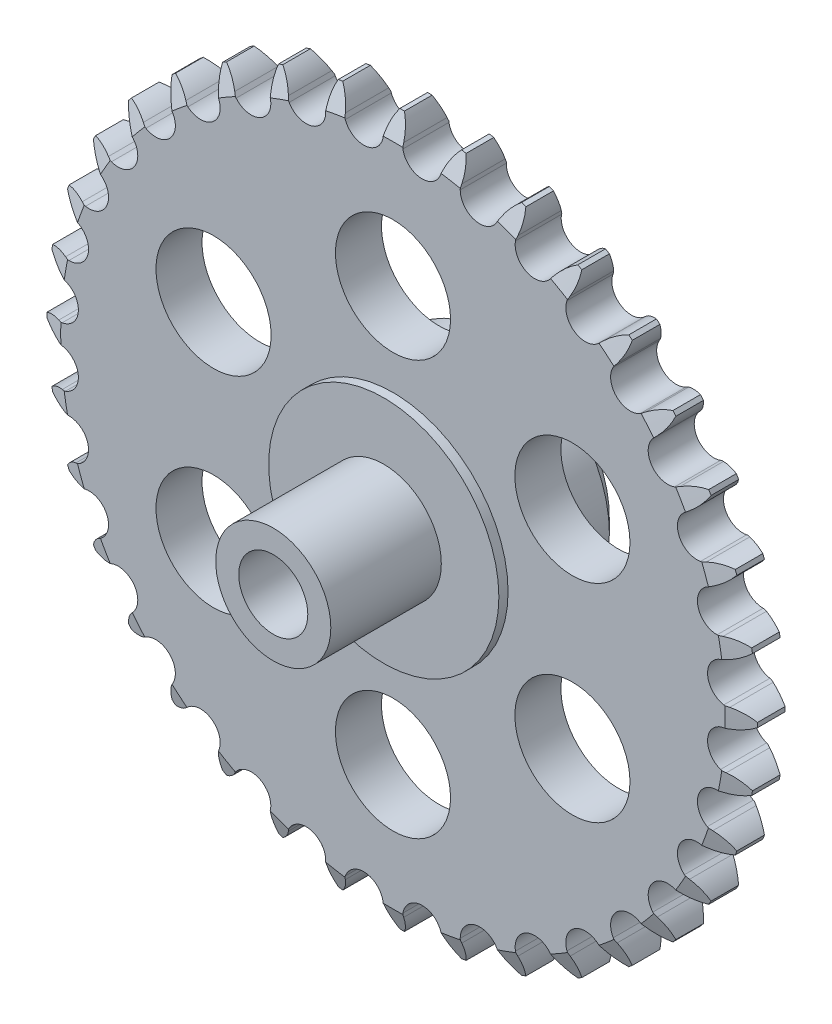
from build123d import *

# Parameters (mm, degrees)
SKETCH2_R                       = 68.60307911
BOSS_EXTRUDE1_DEPTH             = 5
BOSS_EXTRUDE2_REACH             = 99.148
BOSS_EXTRUDE2_DIRECTION_2_REACH = 99.148
CIRPATTERN1_COUNT               = 36
BOSS_EXTRUDE3_DEPTH             = 7
BOSS_EXTRUDE3_DEPTH_BACK        = 20
SKETCH6_R                       = 25
CUT_EXTRUDE1_DEPTH              = 111.942596201
CUT_EXTRUDE1_DEPTH_BACK         = 111.942596201
SKETCH7_R                       = 7.5
SKETCH9_R                       = 12.5
SKETCH9_R_2                     = 7.5
BOSS_EXTRUDE4_DEPTH             = 24
SKETCH8_R                       = 12.5
CUT_EXTRUDE2_DEPTH              = 114.442759363
CIRPATTERN2_COUNT               = 6
CHAMFER1_SIZE                   = 3
CUT_EXTRUDE5_DEPTH              = 3


with BuildPart() as part:
    # Sketch2 → Boss-Extrude1 (new, symmetric)
    with BuildSketch(Plane.XY):
        Circle(SKETCH2_R)
    extrude(amount=BOSS_EXTRUDE1_DEPTH, both=True)

    # Boss-Extrude2: up to this face of the body (flat: up to its plane)
    boss_extrude2_end = Plane(part.part.faces().sort_by_distance((0, 0, 5))[0])
    # Sketch4 → Boss-Extrude2 (add, up to the picked face)
    with BuildSketch(Plane.XY, mode=Mode.PRIVATE) as boss_extrude2_sk1:
        with BuildLine():
            Line((-0.5, 77.163008044), (0.5, 77.163008044))
            ThreePointArc((0.5, 77.163008044), (1.520836, 75.099924668), (2.042896963, 72.85807911))
            Line((2.042896963, 72.85807911), (2.156832572, 71.85807911))
            ThreePointArc((2.156832572, 71.85807911), (3.469336894, 69.449250243), (5.979152315, 68.342023682))
            ThreePointArc((5.979152315, 68.342023682), (0, 68.60307911), (-5.979152315, 68.342023682))
            ThreePointArc((-5.979152315, 68.342023682), (-3.469336894, 69.449250243), (-2.156832572, 71.85807911))
            Line((-2.156832572, 71.85807911), (-2.042896963, 72.85807911))
            ThreePointArc((-2.042896963, 72.85807911), (-1.520836, 75.099924668), (-0.5, 77.163008044))
        make_face()
    boss_extrude2_tool1 = split(extrude(boss_extrude2_sk1.sketch, amount=BOSS_EXTRUDE2_REACH, mode=Mode.PRIVATE), bisect_by=boss_extrude2_end, keep=Keep.BOTH, mode=Mode.PRIVATE)
    boss_extrude2 = boss_extrude2_tool1.solids().sort_by(Axis((0, 71.819777, 0), (0, 0, 1)))[0]
    add(boss_extrude2)

    # Boss-Extrude2 direction 2: up to this face of the body (flat: up to its plane)
    boss_extrude2_direction_2_end = Plane(part.part.faces().sort_by_distance((0, 0, -5))[0])
    # Sketch4 → Boss-Extrude2 direction 2 (add, up to the picked face)
    with BuildSketch(Plane.XY, mode=Mode.PRIVATE) as boss_extrude2_direction_2_sk1:
        with BuildLine():
            Line((-0.5, 77.163008044), (0.5, 77.163008044))
            ThreePointArc((0.5, 77.163008044), (1.520836, 75.099924668), (2.042896963, 72.85807911))
            Line((2.042896963, 72.85807911), (2.156832572, 71.85807911))
            ThreePointArc((2.156832572, 71.85807911), (3.469336894, 69.449250243), (5.979152315, 68.342023682))
            ThreePointArc((5.979152315, 68.342023682), (0, 68.60307911), (-5.979152315, 68.342023682))
            ThreePointArc((-5.979152315, 68.342023682), (-3.469336894, 69.449250243), (-2.156832572, 71.85807911))
            Line((-2.156832572, 71.85807911), (-2.042896963, 72.85807911))
            ThreePointArc((-2.042896963, 72.85807911), (-1.520836, 75.099924668), (-0.5, 77.163008044))
        make_face()
    boss_extrude2_direction_2_tool1 = split(extrude(boss_extrude2_direction_2_sk1.sketch, amount=-BOSS_EXTRUDE2_DIRECTION_2_REACH, mode=Mode.PRIVATE), bisect_by=boss_extrude2_direction_2_end, keep=Keep.BOTH, mode=Mode.PRIVATE)
    boss_extrude2_direction_2 = boss_extrude2_direction_2_tool1.solids().sort_by(Axis((0, 71.819777, 0), (0, 0, -1)))[0]
    add(boss_extrude2_direction_2)

    # CirPattern1: Boss-Extrude2, Boss-Extrude2 direction 2 ×36 about axis
    cirpattern1_axis = Axis((0, 0, 5), (0, 0, -1))
    add([boss_extrude2.rotate(cirpattern1_axis, i * 360 / CIRPATTERN1_COUNT) for i in range(1, CIRPATTERN1_COUNT)])
    add([boss_extrude2_direction_2.rotate(cirpattern1_axis, i * 360 / CIRPATTERN1_COUNT) for i in range(1, CIRPATTERN1_COUNT)])

    # Sketch5 → Cut-Revolve7 (revolve, cut)
    with BuildSketch(Plane(origin=(0, 0, 0), x_dir=(0, 0, -1), z_dir=(1, 0, 0))):
        Polygon((6, 84.663008044), (0, 84.663008044), (6, 69.663008044), align=None)
        Polygon((0, 84.663008044), (-6, 84.663008044), (-6, 69.663008044), align=None)
    revolve(axis=Axis((0, 0, 0), (0, 0, 1)), mode=Mode.SUBTRACT)

    # Sketch6 → Boss-Extrude3 (add, two sides: drawn at the far end of the back side and taken through both)
    with BuildSketch(Plane.XY.offset(-BOSS_EXTRUDE3_DEPTH_BACK)):
        Circle(SKETCH6_R)
    extrude(amount=BOSS_EXTRUDE3_DEPTH + BOSS_EXTRUDE3_DEPTH_BACK)

    # Sketch7 → Cut-Extrude1 (cut, two sides: drawn at the far end of the back side and taken through both)
    with BuildSketch(Plane.XY.offset(-CUT_EXTRUDE1_DEPTH_BACK)):
        Circle(SKETCH7_R)
    extrude(amount=CUT_EXTRUDE1_DEPTH + CUT_EXTRUDE1_DEPTH_BACK, mode=Mode.SUBTRACT)

    # Sketch9 → Boss-Extrude4 (add)
    with BuildSketch(Plane.XY.offset(7)):
        Circle(SKETCH9_R)
        Circle(SKETCH9_R_2, mode=Mode.SUBTRACT)
    extrude(amount=BOSS_EXTRUDE4_DEPTH)

    # Sketch8 → Cut-Extrude2 (cut, symmetric)
    with BuildSketch(Plane.XY):
        with Locations((0, 45)):
            Circle(SKETCH8_R)
    cut_extrude2 = extrude(amount=CUT_EXTRUDE2_DEPTH, both=True, mode=Mode.SUBTRACT)

    # CirPattern2: Cut-Extrude2 ×6 about axis
    cirpattern2_axis = Axis((0, 0, 6), (0, 0, 1))
    for i in range(1, CIRPATTERN2_COUNT):
        add(cut_extrude2.rotate(cirpattern2_axis, i * 360 / CIRPATTERN2_COUNT), mode=Mode.SUBTRACT)

    # Chamfer1
    chamfer1_edges = [part.edges().sort_by_distance(p)[0] for p in [
        (-25, 0, -20),
    ]]
    chamfer(chamfer1_edges, length=CHAMFER1_SIZE)

    # Sketch10 → Cut-Extrude5 (cut)
    with BuildSketch(Plane(origin=(0, 0, -20), x_dir=(-1, 0, 0), z_dir=(0, 0, -1))):
        with BuildLine():
            Line((14.046031564, -3.790230658), (29.006151541, -2.481389755))
            Line((29.006151541, -2.481389755), (28.134594114, 7.480557226))
            Line((28.134594114, 7.480557226), (13.174474136, 6.171716323))
            ThreePointArc((13.174474136, 6.171716323), (14.493070053, 1.267979329), (14.046031564, -3.790230658))
        make_face()
    extrude(amount=-CUT_EXTRUDE5_DEPTH, mode=Mode.SUBTRACT)


solid = part.part
